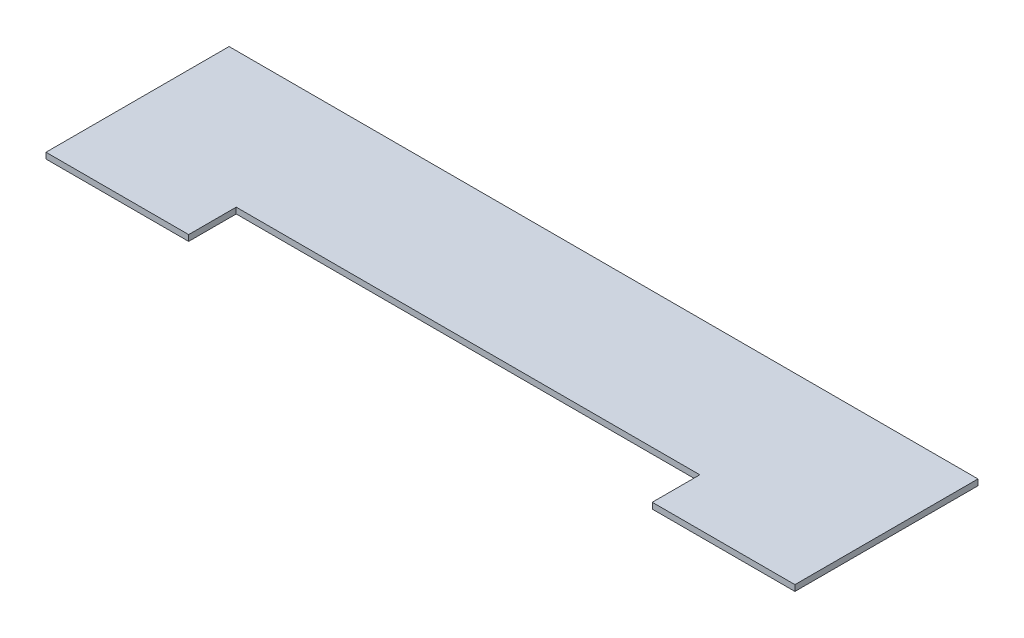
from build123d import *

# Parameters (mm, degrees)
SKETCH1_W           = 800.1
SKETCH1_H           = 195.58
BOSS_EXTRUDE2_DEPTH = 6.35
SKETCH3_W           = 495.3
SKETCH3_H           = 50.8
CUT_EXTRUDE1_DEPTH  = 6.35


with BuildPart() as part:
    # Sketch1 → Boss-Extrude2 (new body)
    with BuildSketch(Plane(origin=(0, 0, 0), x_dir=(1, 0, 0), z_dir=(0, 1, 0))):
        with Locations((400.05, 97.79)):
            Rectangle(SKETCH1_W, SKETCH1_H)
    extrude(amount=BOSS_EXTRUDE2_DEPTH)

    # Sketch3 → Cut-Extrude1 (cut)
    with BuildSketch(Plane(origin=(0, 6.35, 0), x_dir=(1, 0, 0), z_dir=(0, 1, 0))):
        with Locations((400.05, 25.4)):
            Rectangle(SKETCH3_W, SKETCH3_H)
    extrude(amount=-CUT_EXTRUDE1_DEPTH, mode=Mode.SUBTRACT)


solid = part.part
